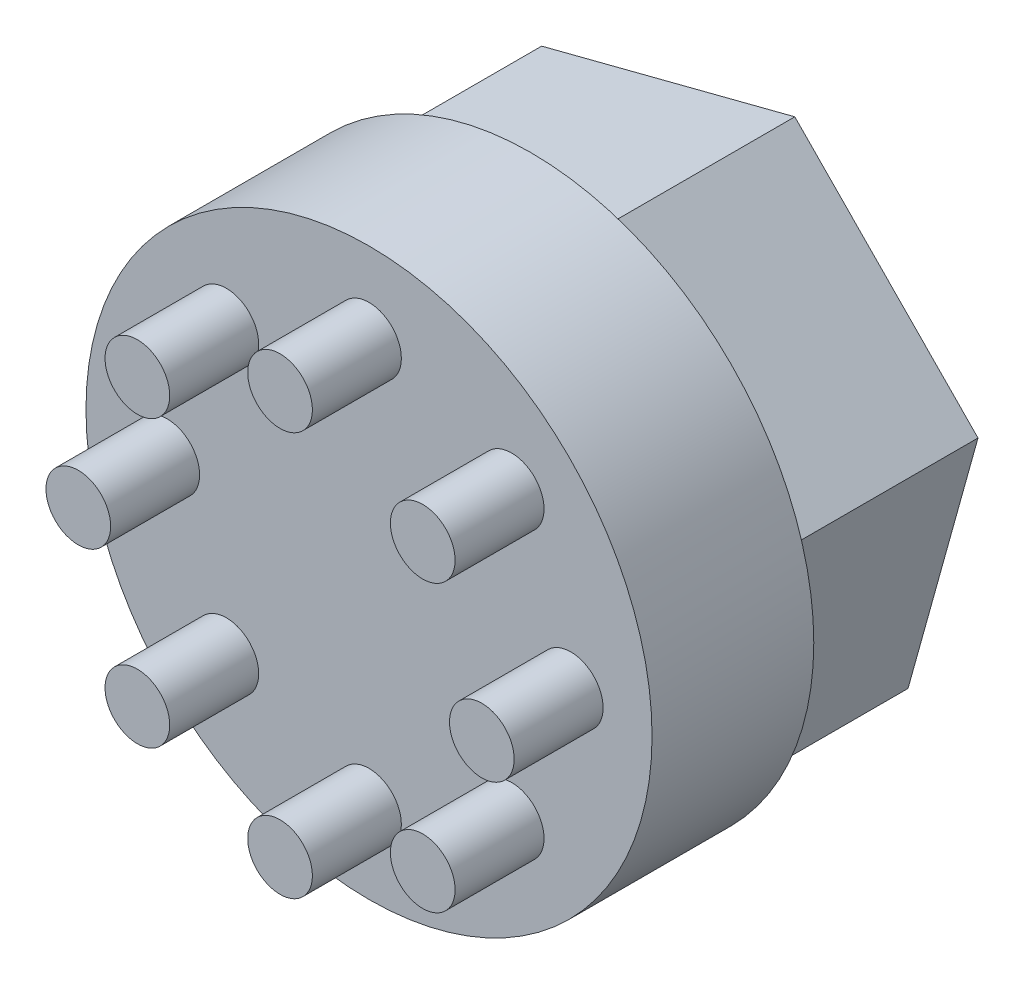
from build123d import *

# Parameters (mm, degrees)
ESQUISSE1_R        = 17.5
BOSS_EXTRU_1_DEPTH = 10
ESQUISSE2_R        = 2
BOSS_EXTRU_2_DEPTH = 5.5
BOSS_EXTRU_3_DEPTH = 12


with BuildPart() as part:
    # Esquisse1 → Boss.-Extru.1 (new body)
    with BuildSketch(Plane.XY):
        Circle(ESQUISSE1_R)
    extrude(amount=BOSS_EXTRU_1_DEPTH)

    # Esquisse2 → Boss.-Extru.2 (add)
    with BuildSketch(Plane.XY.offset(10)):
        with Locations((8.821157095, 8.821157095)):
            Circle(ESQUISSE2_R)
        with Locations((0, 12.475)):
            Circle(ESQUISSE2_R)
        with Locations((12.475, 0)):
            Circle(ESQUISSE2_R)
        with Locations((8.821157095, -8.821157095)):
            Circle(ESQUISSE2_R)
        with Locations((0, -12.475)):
            Circle(ESQUISSE2_R)
        with Locations((-8.821157095, -8.821157095)):
            Circle(ESQUISSE2_R)
        with Locations((-12.475, 0)):
            Circle(ESQUISSE2_R)
        with Locations((-8.821157095, 8.821157095)):
            Circle(ESQUISSE2_R)
    extrude(amount=BOSS_EXTRU_2_DEPTH)

    # Esquisse3 → Boss.-Extru.3 (add)
    with BuildSketch(Plane(origin=(0, 0, 0), x_dir=(-1, 0, 0), z_dir=(0, 0, -1))):
        Polygon((11.325586205, 11.535355671), (-4.32711795, 15.575923202), (-15.652704155, 4.040567531), (-11.325586205, -11.535355671), (4.32711795, -15.575923202), (15.652704155, -4.040567531), align=None)
    extrude(amount=BOSS_EXTRU_3_DEPTH)


solid = part.part
